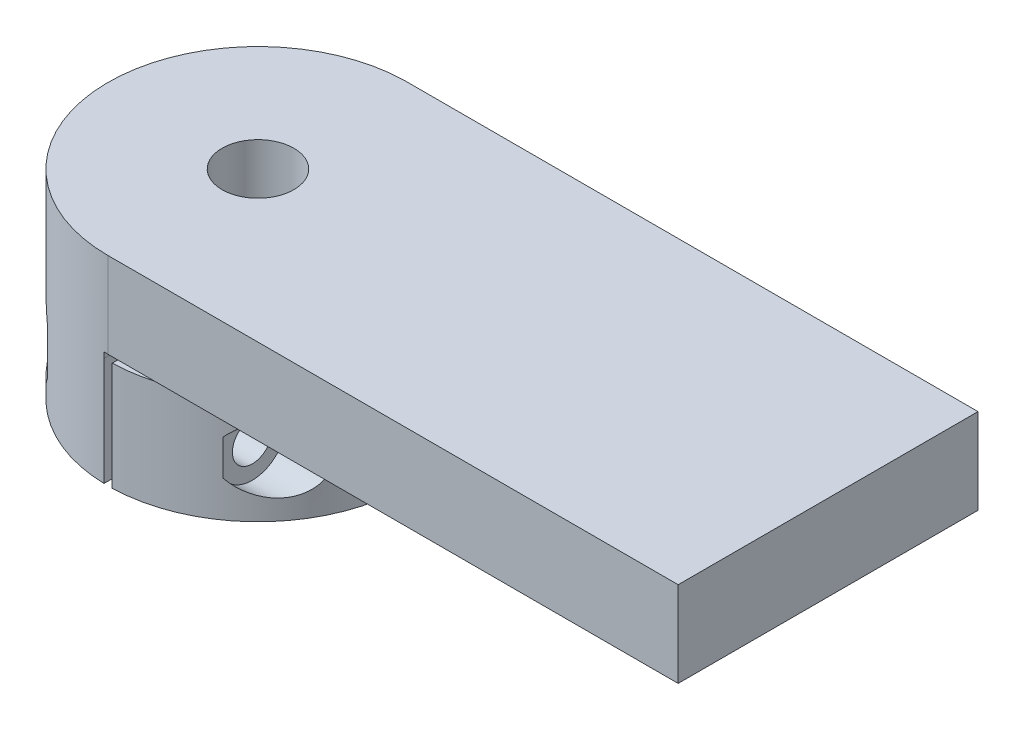
from build123d import *

# Parameters (mm, degrees)
BOSS_EXTRUDE1_DEPTH   = 9.5
BOSS_EXTRUDE1_2_DEPTH = 9.5
SKETCH2_R             = 3
CUT_EXTRUDE1_DEPTH    = 5.5
CUT_EXTRUDE2_START    = -21.8
SKETCH3_R             = 1.75
CUT_EXTRUDE2_DEPTH    = 28.3000001
SKETCH5_R             = 3.15
BOSS_EXTRUDE2_DEPTH   = 8
SKETCH6_W             = 50.365277778
SKETCH6_H             = 0.5
CUT_EXTRUDE3_DEPTH    = 27.294925719
SKETCH15_R            = 1.93
CUT_EXTRUDE12_DEPTH   = 14.054128206
CUT_EXTRUDE14_DEPTH   = 5


with BuildPart() as part:
    # Sketch1 → Boss-Extrude1 (new body)
    with BuildSketch(Plane(origin=(0, 0, 0), x_dir=(1, 0, 0), z_dir=(0, 1, 0))):
        with BuildLine():
            Line((-0.2625, 3.139043445), (-0.365277778, 13.144925719))
            ThreePointArc((-0.365277778, 13.144925719), (-13.15, 0), (-0.365277778, -13.144925719))
            Line((-0.365277778, -13.144925719), (-0.2625, -3.139043445))
            ThreePointArc((-0.2625, -3.139043445), (-3.15, 0), (-0.2625, 3.139043445))
        make_face()
    extrude(amount=BOSS_EXTRUDE1_DEPTH)


with BuildPart() as body_2:
    # Sketch1 → Boss-Extrude1 2 (new body)
    with BuildSketch(Plane(origin=(0, 0, 0), x_dir=(1, 0, 0), z_dir=(0, 1, 0))):
        with BuildLine():
            Line((0.2625, 3.139043445), (0.365277778, 13.144925719))
            ThreePointArc((0.365277778, 13.144925719), (13.15, 0), (0.365277778, -13.144925719))
            Line((0.365277778, -13.144925719), (0.2625, -3.139043445))
            ThreePointArc((0.2625, -3.139043445), (3.15, 0), (0.2625, 3.139043445))
        make_face()
    extrude(amount=BOSS_EXTRUDE1_2_DEPTH)

    # Sketch2 → Cut-Extrude1 (cut)
    with BuildSketch(Plane(origin=(13.15, 0, 0), x_dir=(0, 0, -1), z_dir=(1, 0, 0))):
        with Locations((8.141984582, 4.75)):
            Circle(SKETCH2_R)
    cut_extrude1 = extrude(amount=-CUT_EXTRUDE1_DEPTH, mode=Mode.SUBTRACT)


with BuildPart() as cut_extrude2_tool:
    # Sketch3 → Cut-Extrude2 (new body)
    with BuildSketch(Plane(origin=(7.65, 0, 0), x_dir=(0, 0, -1), z_dir=(1, 0, 0)).offset(CUT_EXTRUDE2_START)):
        with Locations((8.141984582, 4.75)):
            Circle(SKETCH3_R)
    cut_extrude2 = extrude(amount=CUT_EXTRUDE2_DEPTH)


with BuildPart() as part_1:
    add(part.part)

    # Cut-Extrude2: cut by cut_extrude2_tool
    add(cut_extrude2_tool.part, mode=Mode.SUBTRACT)

    # Sketch5 → Boss-Extrude2 (add)
    with BuildSketch(Plane(origin=(0, 9.5, 0), x_dir=(1, 0, 0), z_dir=(0, 1, 0))):
        with BuildLine():
            ThreePointArc((-0.365277778, 13.144925719), (-13.148731368, -0.18265651), (0, -13.15))
            Line((0, -13.15), (50, -13.15))
            Line((50, -13.15), (50, 13.144925719))
            Line((50, 13.144925719), (0.365277778, 13.144925719))
            Line((0.365277778, 13.144925719), (-0.365277778, 13.144925719))
        make_face()
        Circle(SKETCH5_R, mode=Mode.SUBTRACT)
    extrude(amount=BOSS_EXTRUDE2_DEPTH)

    # Sketch6 → Cut-Extrude3 (cut, through all)
    with BuildSketch(Plane(origin=(0, 0, -13.144925719), x_dir=(-1, 0, 0), z_dir=(0, 0, -1))):
        with Locations((-24.817361111, 9.75)):
            Rectangle(SKETCH6_W, SKETCH6_H)
    extrude(amount=-CUT_EXTRUDE3_DEPTH, mode=Mode.SUBTRACT)

    # Sketch15 → Cut-Extrude12 (cut, through all)
    with BuildSketch(Plane(origin=(-0.230232284, 0, 0.002364885), x_dir=(-0.010271194, 0, -0.99994725), z_dir=(0.99994725, 0, -0.010271194))):
        with Locations((8.062980458, 4.75)):
            Circle(SKETCH15_R)
    cut_extrude12 = extrude(amount=-CUT_EXTRUDE12_DEPTH, mode=Mode.SUBTRACT)


with BuildPart() as body_2_1:
    add(body_2.part)

    # Cut-Extrude2: cut by cut_extrude2_tool
    add(cut_extrude2_tool.part, mode=Mode.SUBTRACT)


with BuildPart() as mirror11_tool:
    # Mirror11: Cut-Extrude1, Cut-Extrude2, Cut-Extrude12 across plane
    add(cut_extrude1.mirror(Plane.XY))
    add(cut_extrude2.mirror(Plane.XY))
    add(cut_extrude12.mirror(Plane.XY))


with BuildPart() as part_2:
    add(part_1.part)

    # Mirror11: cut by mirror11_tool
    add(mirror11_tool.part, mode=Mode.SUBTRACT)

    # Sketch16 → Cut-Extrude14 (cut)
    with BuildSketch(Plane.ZY.offset(13.15)):
        Polygon((9.792241058, 7.75), (6.328139443, 7.75), (4.596088635, 4.75), (6.328139443, 1.75), (9.792241058, 1.75), (11.524291865, 4.75), align=None)
        Polygon((-4.596088635, 4.75), (-6.328139443, 7.75), (-9.792241058, 7.75), (-11.524291865, 4.75), (-9.792241058, 1.75), (-6.328139443, 1.75), align=None)
    extrude(amount=-CUT_EXTRUDE14_DEPTH, mode=Mode.SUBTRACT)


with BuildPart() as body_2_2:
    add(body_2_1.part)

    # Mirror11: cut by mirror11_tool
    add(mirror11_tool.part, mode=Mode.SUBTRACT)


solid = Compound([part_2.part, body_2_2.part])
